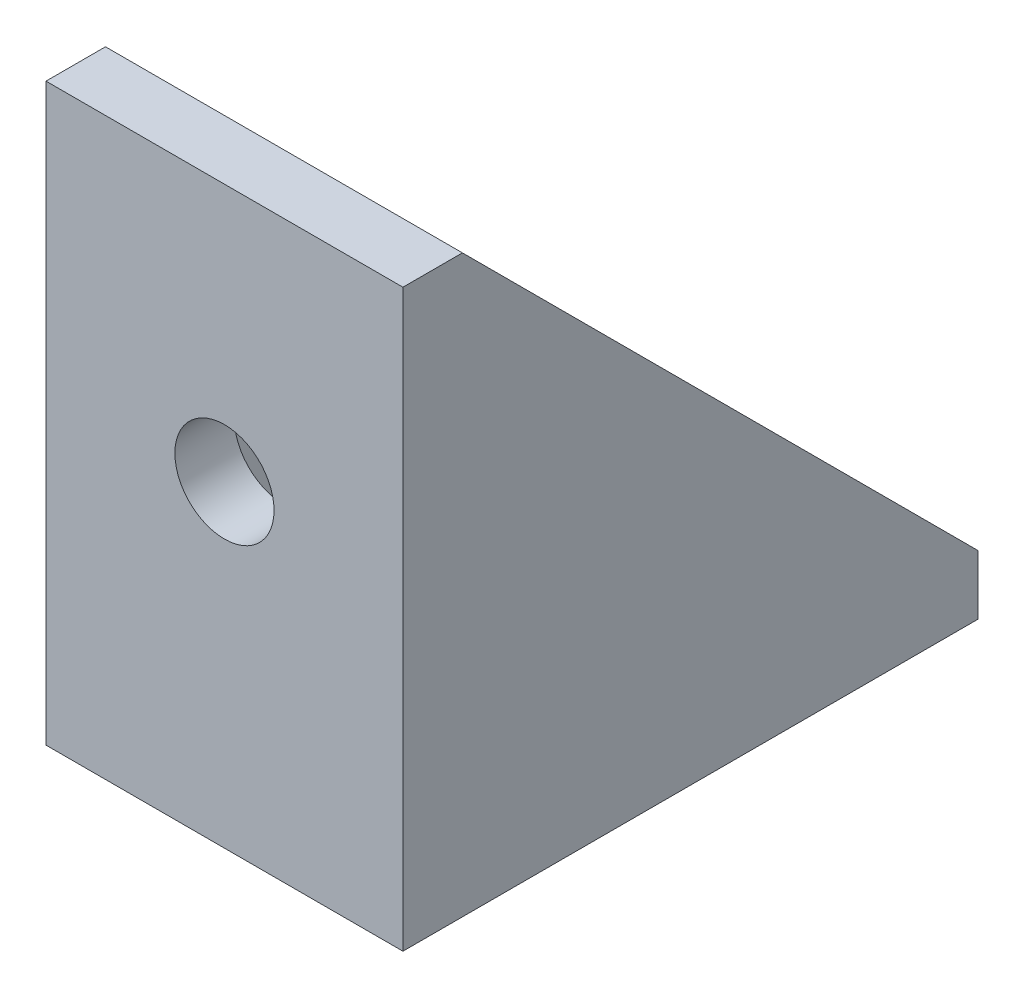
from build123d import *

# Parameters (mm, degrees)
EXTRUDE_THIN1_DEPTH      = 9
EXTRUDE_THIN1_DEPTH_BACK = 9
RIB1_REACH               = 46.788
SKETCH2_WALL_W           = 128.346335328
SKETCH2_WALL_H           = 2
SKETCH3_R                = 2.5
CUT_EXTRUDE1_DEPTH       = 10
SKETCH4_R                = 2.5
CUT_EXTRUDE2_DEPTH       = 10


with BuildPart() as part:
    # Sketch1 → Extrude-Thin1 (new, two sides)
    with BuildSketch(Plane(origin=(0, 0, 0), x_dir=(0, 0, -1), z_dir=(1, 0, 0))) as extrude_thin1_sk:
        Polygon((0, 29), (0, 0), (29, 0), (29, 3), (3, 3), (3, 29), align=None)
    extrude(amount=EXTRUDE_THIN1_DEPTH)
    extrude(extrude_thin1_sk.sketch, amount=-EXTRUDE_THIN1_DEPTH_BACK)

    # Sketch2 wall → Rib1 (add, up to next)
    with BuildSketch(Plane(origin=(9, 16, -16), x_dir=(0, -0.707106781187, -0.707106781187), z_dir=(0, 0.707106781187, -0.707106781187)), mode=Mode.PRIVATE) as rib1_sk1:
        with Locations((0, 1)):
            Rectangle(SKETCH2_WALL_W, SKETCH2_WALL_H)
    rib1_tool1 = extrude(rib1_sk1.sketch, amount=-RIB1_REACH, mode=Mode.PRIVATE) - part.part
    rib1 = rib1_tool1.solids().sort_by_distance((9, 16, -16))[0]
    add(rib1)

    # Mirror1: Rib1 across plane
    add(rib1.mirror(Plane(origin=(0, 0, 0), x_dir=(0, 0, 1), z_dir=(1, 0, 0))))

    # Sketch3 → Cut-Extrude1 (cut)
    with BuildSketch(Plane(origin=(0, 3, 0), x_dir=(1, 0, 0), z_dir=(0, 1, 0))):
        with Locations(Location((0, 16, 0), (0, 0, 270))):
            Circle(SKETCH3_R)
    extrude(amount=-CUT_EXTRUDE1_DEPTH, mode=Mode.SUBTRACT)

    # Sketch4 → Cut-Extrude2 (cut)
    with BuildSketch(Plane(origin=(0, 0, -3), x_dir=(-1, 0, 0), z_dir=(0, 0, -1))):
        with Locations(Location((0, 16, 0), (0, 0, 90))):
            Circle(SKETCH4_R)
    extrude(amount=-CUT_EXTRUDE2_DEPTH, mode=Mode.SUBTRACT)


solid = part.part
